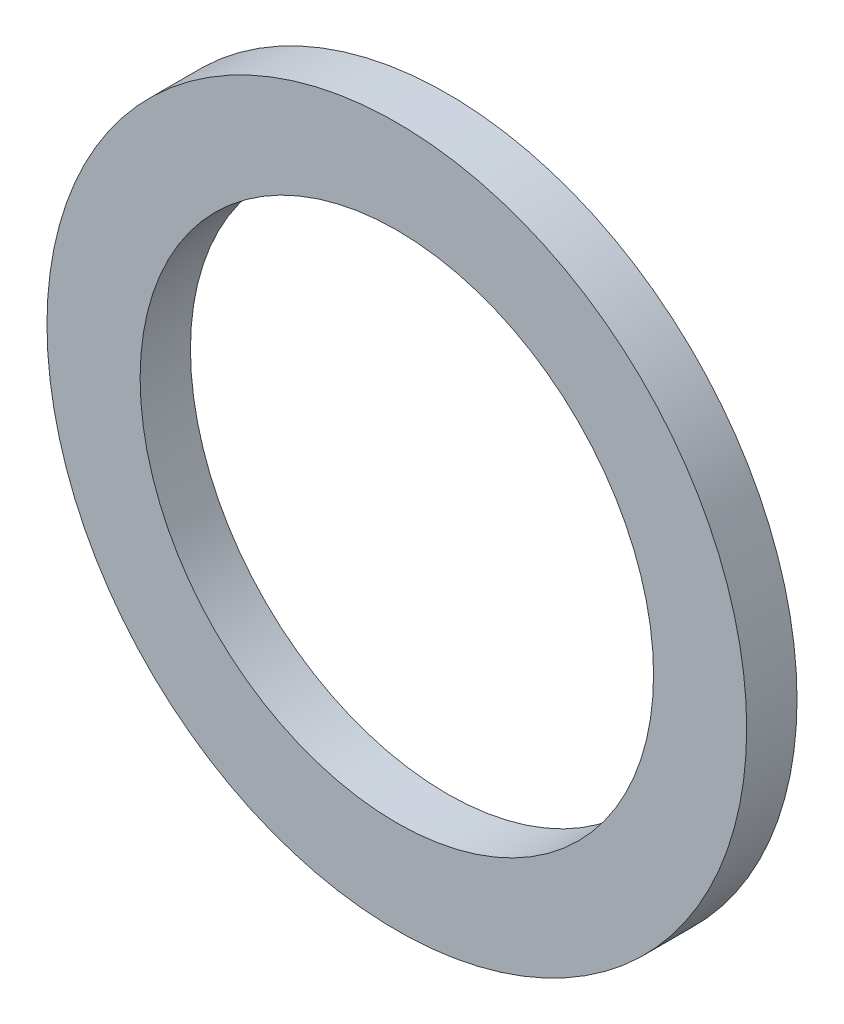
from build123d import *

# Parameters (mm, degrees)
SKETCH3_R           = 6.95
SKETCH3_R_2         = 5.1
BOSS_EXTRUDE1_DEPTH = 0.5


with BuildPart() as part:
    # Sketch3 → Boss-Extrude1 (new body, symmetric)
    with BuildSketch(Plane.XY):
        Circle(SKETCH3_R)
        Circle(SKETCH3_R_2, mode=Mode.SUBTRACT)
    extrude(amount=BOSS_EXTRUDE1_DEPTH, both=True)


solid = part.part
